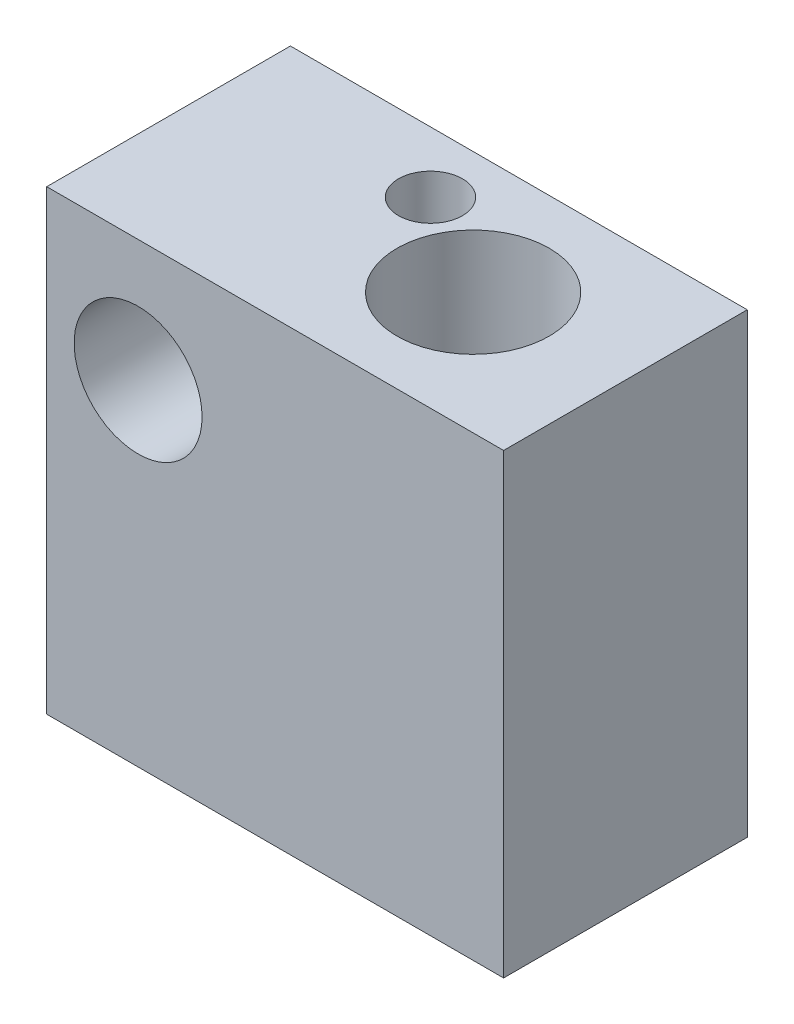
from build123d import *

# Parameters (mm, degrees)
SKETCH1_W           = 15
SKETCH1_H           = 15
SKETCH1_R           = 2.1
BOSS_EXTRUDE1_DEPTH = 8
SKETCH2_R           = 2.5
CUT_EXTRUDE1_DEPTH  = 16
SKETCH3_R           = 1.05
CUT_EXTRUDE2_DEPTH  = 16


with BuildPart() as part:
    # Sketch1 → Boss-Extrude1 (new body)
    with BuildSketch(Plane.XY):
        with Locations((4.5, -3.5)):
            Rectangle(SKETCH1_W, SKETCH1_H)
        Circle(SKETCH1_R, mode=Mode.SUBTRACT)
    extrude(amount=BOSS_EXTRUDE1_DEPTH)

    # Sketch2 → Cut-Extrude1 (cut, through all)
    with BuildSketch(Plane.XZ.offset(11)):
        with Locations((7, 4)):
            Circle(SKETCH2_R)
    extrude(amount=-CUT_EXTRUDE1_DEPTH, mode=Mode.SUBTRACT)

    # Sketch3 → Cut-Extrude2 (cut, through all)
    with BuildSketch(Plane.XZ.offset(11)):
        with Locations((3.6, 2)):
            Circle(SKETCH3_R)
    extrude(amount=-CUT_EXTRUDE2_DEPTH, mode=Mode.SUBTRACT)


solid = part.part
